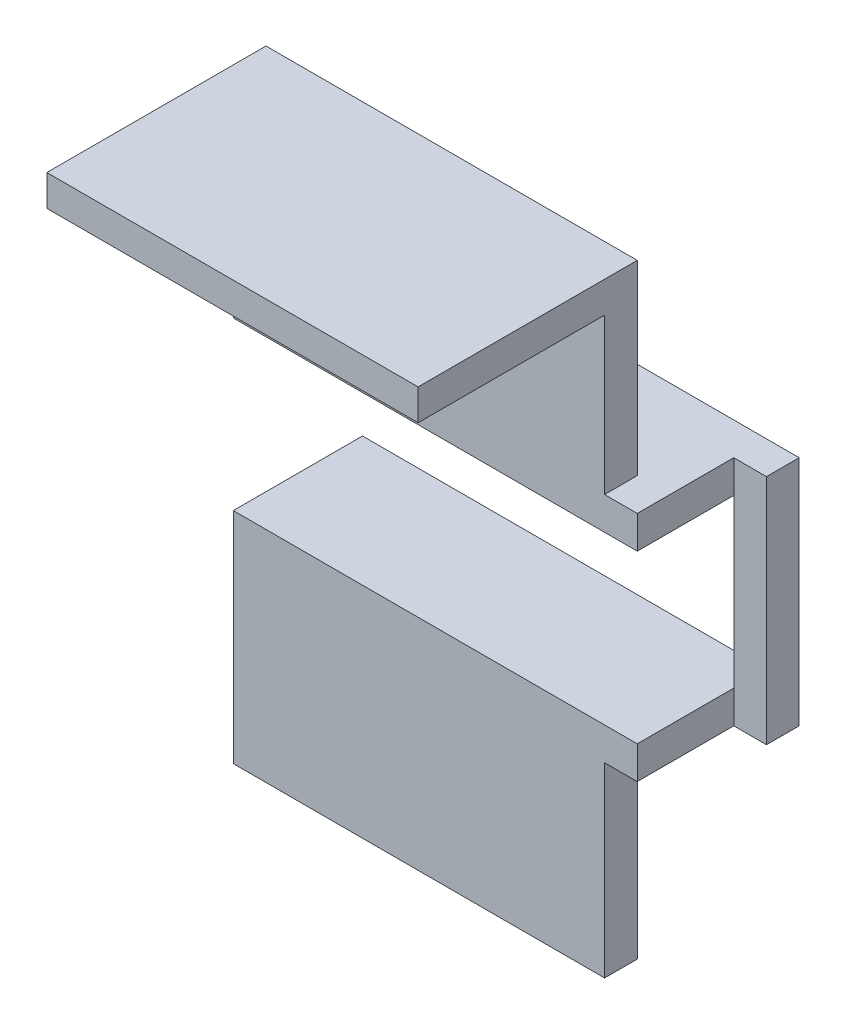
from build123d import *

# Parameters (mm, degrees)
SKETCH_1_W       = 11.8
SKETCH_1_H       = 22.8
EXTRUDE_1_DEPTH  = 4
SKETCH_2_W       = 15.8
SKETCH_2_H       = 4
EXTRUDE_2_DEPTH  = 2
SKETCH_5_W       = 15.8
SKETCH_5_H       = 4
EXTRUDE_4_DEPTH  = 2
SKETCH_6_W       = 15.8
SKETCH_6_H       = 4
EXTRUDE_5_DEPTH  = 11.8
SKETCH_7_W       = 4
SKETCH_7_H       = 14.2
EXTRUDE_7_DEPTH  = 4
SKETCH_8_W       = 4
SKETCH_8_H       = 22.8
EXTRUDE_8_DEPTH  = 33.6
SKETCH_10_W      = 15.8
SKETCH_10_H      = 4
EXTRUDE_9_DEPTH  = 33.6
SKETCH_11_W      = 15.8
SKETCH_11_H      = 4
EXTRUDE_10_DEPTH = 33.6
SKETCH_12_W      = 45.4
SKETCH_12_H      = 3.8
EXTRUDE_11_DEPTH = 22.8


with BuildPart() as part:
    # 스케치1 → 보스-돌출1 (new body)
    with BuildSketch(Plane.XY):
        Rectangle(SKETCH_1_W, SKETCH_1_H)
    extrude(amount=EXTRUDE_1_DEPTH)

    # 스케치2 → 보스-돌출2 (add)
    with BuildSketch(Plane(origin=(0, 11.4, 0), x_dir=(1, 0, 0), z_dir=(0, 1, 0))):
        with Locations((2, -2)):
            Rectangle(SKETCH_2_W, SKETCH_2_H)
    extrude(amount=EXTRUDE_2_DEPTH)

    # 스케치5 → 보스-돌출4 (add)
    with BuildSketch(Plane(origin=(0, 13.4, 0), x_dir=(1, 0, 0), z_dir=(0, 1, 0))):
        with Locations((2, -2)):
            Rectangle(SKETCH_5_W, SKETCH_5_H)
    extrude(amount=EXTRUDE_4_DEPTH)

    # 스케치6 → 보스-돌출5 (add)
    with BuildSketch(Plane(origin=(0, 0, 0), x_dir=(-1, 0, 0), z_dir=(0, 0, -1))):
        with Locations((-2, 13.4)):
            Rectangle(SKETCH_6_W, SKETCH_6_H)
    extrude(amount=EXTRUDE_5_DEPTH)

    # 스케치7 → 보스-돌출7 (add)
    with BuildSketch(Plane(origin=(9.9, 0, 0), x_dir=(0, 0, -1), z_dir=(1, 0, 0))):
        with Locations((9.8, 18.5)):
            Rectangle(SKETCH_7_W, SKETCH_7_H)
    extrude(amount=EXTRUDE_7_DEPTH)

    # 스케치8 → 보스-돌출8 (add)
    with BuildSketch(Plane.ZY.offset(5.9)):
        with Locations((2, 0)):
            Rectangle(SKETCH_8_W, SKETCH_8_H)
    extrude(amount=EXTRUDE_8_DEPTH)

    # 대칭 복사3: part across plane


with BuildPart() as part_1:
    add(part.part)
    add(part.part.mirror(Plane(origin=(13.9, 25.6, -11.8), x_dir=(0, 0, 1), z_dir=(0, -1, 0))))

    # 스케치10 → 보스-돌출9 (add)
    with BuildSketch(Plane.ZY.offset(5.9)):
        with Locations((-3.9, 13.4)):
            Rectangle(SKETCH_10_W, SKETCH_10_H)
    extrude(amount=EXTRUDE_9_DEPTH)

    # 스케치11 → 보스-돌출10 (add)
    with BuildSketch(Plane.ZY.offset(5.9)):
        with Locations((-3.9, 37.8)):
            Rectangle(SKETCH_11_W, SKETCH_11_H)
    extrude(amount=EXTRUDE_10_DEPTH)

    # 스케치12 → 보스-돌출11 (add)
    with BuildSketch(Plane.XY.offset(4)):
        with Locations((-16.8, 60.7)):
            Rectangle(SKETCH_12_W, SKETCH_12_H)
    extrude(amount=EXTRUDE_11_DEPTH)


solid = part_1.part
